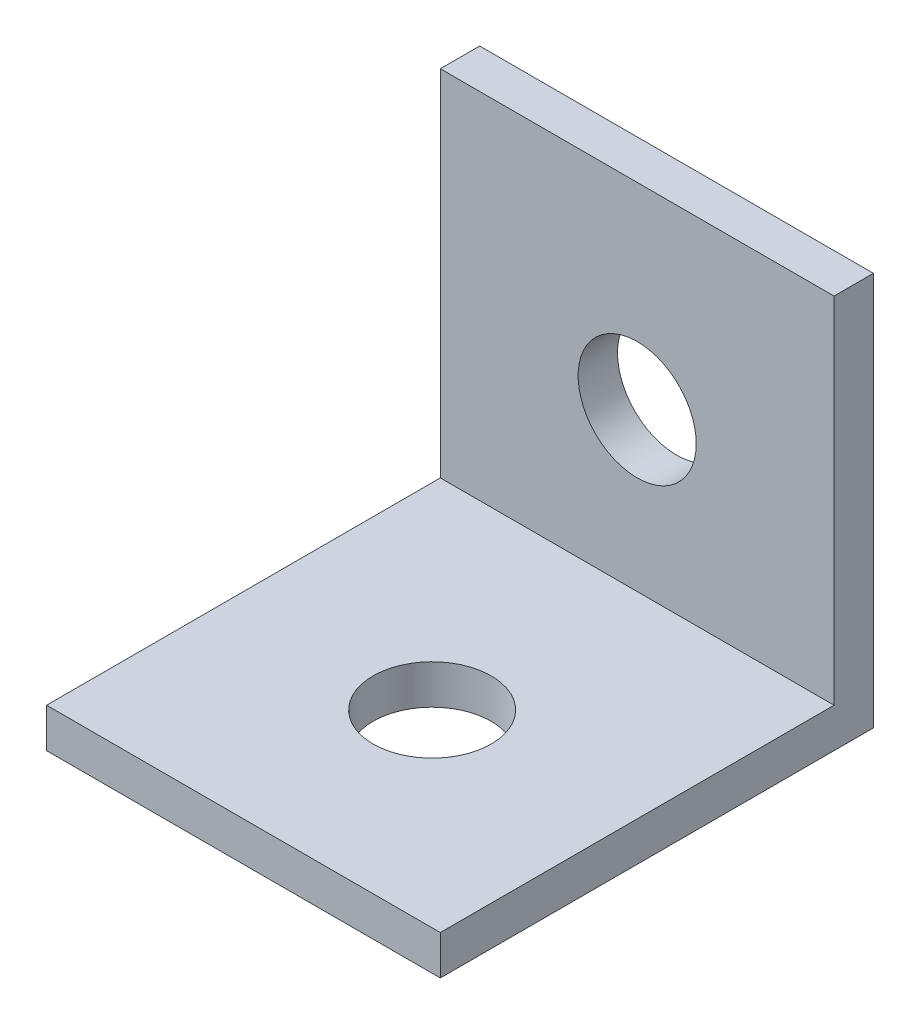
from build123d import *

# Parameters (mm, degrees)
SKETCH2_W           = 20
SKETCH2_H           = 20
BOSS_EXTRUDE1_DEPTH = 2
SKETCH3_W           = 20
SKETCH3_H           = 2
BOSS_EXTRUDE2_DEPTH = 20
SKETCH4_R           = 3
CUT_EXTRUDE1_DEPTH  = 10
SKETCH5_R           = 3
CUT_EXTRUDE2_DEPTH  = 10


with BuildPart() as part:
    # Sketch2 → Boss-Extrude1 (new body)
    with BuildSketch(Plane.XY):
        with Locations((10, 10)):
            Rectangle(SKETCH2_W, SKETCH2_H)
    extrude(amount=BOSS_EXTRUDE1_DEPTH)

    # Sketch3 → Boss-Extrude2 (add)
    with BuildSketch(Plane.XY.offset(2)):
        with Locations((10, 1)):
            Rectangle(SKETCH3_W, SKETCH3_H)
    extrude(amount=BOSS_EXTRUDE2_DEPTH)

    # Sketch4 → Cut-Extrude1 (cut)
    with BuildSketch(Plane(origin=(0, 2, 0), x_dir=(1, 0, 0), z_dir=(0, 1, 0))):
        with Locations((10, -12.415090131)):
            Circle(SKETCH4_R)
    extrude(amount=-CUT_EXTRUDE1_DEPTH, mode=Mode.SUBTRACT)

    # Sketch5 → Cut-Extrude2 (cut)
    with BuildSketch(Plane.XY.offset(2)):
        with Locations((10, 10)):
            Circle(SKETCH5_R)
    extrude(amount=-CUT_EXTRUDE2_DEPTH, mode=Mode.SUBTRACT)


solid = part.part
